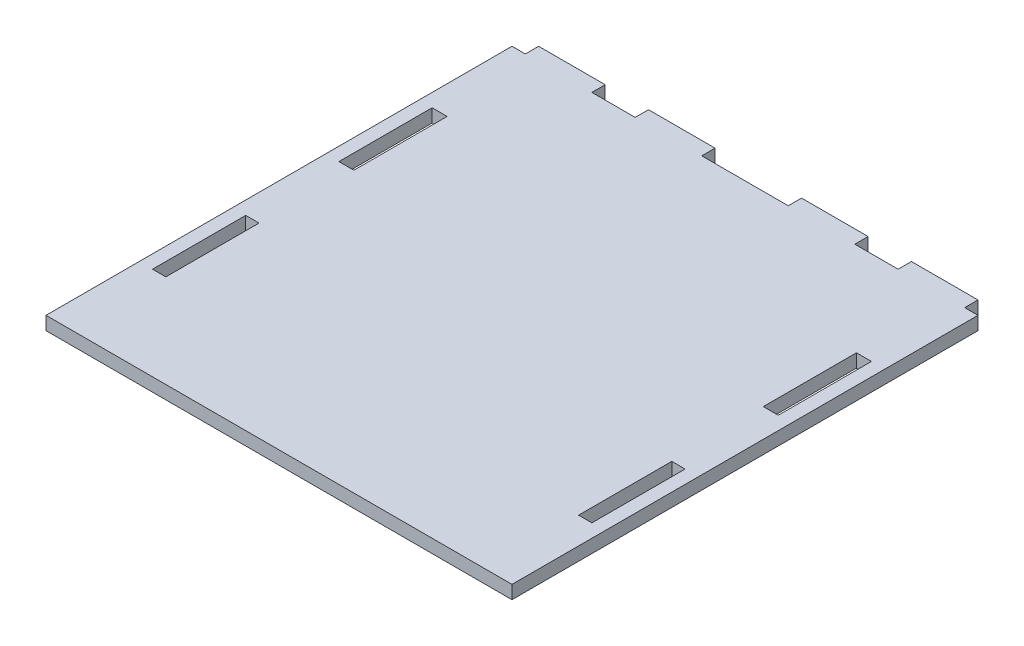
from build123d import *

# Parameters (mm, degrees)
SKETCH1_W           = 6.758532652
SKETCH1_H           = 42
SKETCH1_W_2         = 6
SKETCH1_W_3         = 6.758532653
BOSS_EXTRUDE1_DEPTH = 6


with BuildPart() as part:
    # Sketch1 → Boss-Extrude1 (new body)
    with BuildSketch(Plane(origin=(0, 0, 0), x_dir=(1, 0, 0), z_dir=(0, 1, 0))):
        Polygon((-88.584070796, 61.946902655), (-88.584070796, -148.053097345), (121.415929204, -148.053097345), (121.415929204, 61.946902655), (115.415929204, 61.946902655), (115.415929204, 67.946902655), (85.415929204, 67.946902655), (85.415929204, 61.946902655), (65.915929204, 61.946902655), (65.915929204, 67.946902655), (35.915929204, 67.946902655), (35.915929204, 61.946902655), (-3.084070796, 61.946902655), (-3.084070796, 67.946902655), (-33.084070796, 67.946902655), (-33.084070796, 61.946902655), (-52.584070796, 61.946902655), (-52.584070796, 67.946902655), (-82.584070796, 67.946902655), (-82.584070796, 61.946902655), align=None)
        with Locations((-79.20480447, -1.053097345)):
            Rectangle(SKETCH1_W, SKETCH1_H, mode=Mode.SUBTRACT)
        with Locations((-79.584070796, -85.053097345)):
            Rectangle(SKETCH1_W_2, SKETCH1_H, mode=Mode.SUBTRACT)
        with Locations((112.036662878, -1.053097345)):
            Rectangle(SKETCH1_W_3, SKETCH1_H, mode=Mode.SUBTRACT)
        with Locations((112.415929204, -85.053097345)):
            Rectangle(SKETCH1_W_2, SKETCH1_H, mode=Mode.SUBTRACT)
    extrude(amount=BOSS_EXTRUDE1_DEPTH)


solid = part.part
